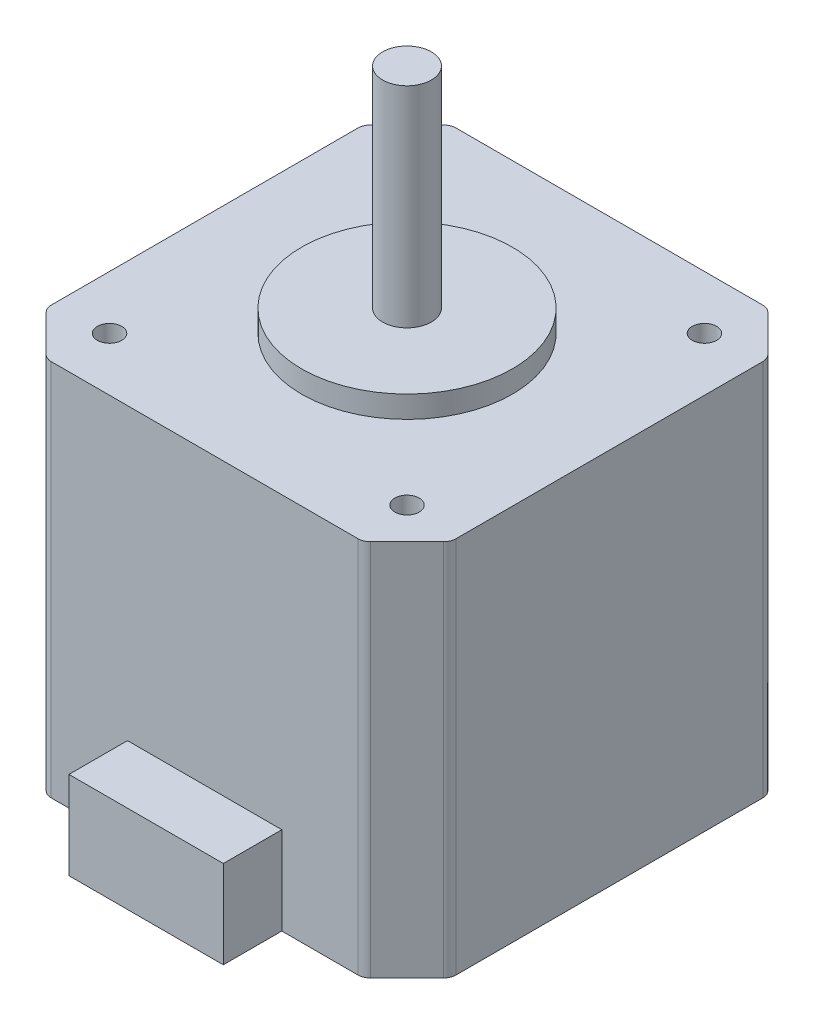
from build123d import *

# Parameters (mm, degrees)
BOSS_EXTRUDE1_DEPTH = 39.37
SKETCH1_3_W         = 16.0782
SKETCH1_3_H         = 6.096
BOSS_EXTRUDE2_DEPTH = 9.144
SKETCH2_R           = 10.9855
BOSS_EXTRUDE3_DEPTH = 2.286
SKETCH3_R           = 2.54
BOSS_EXTRUDE4_DEPTH = 21.844
SKETCH4_R           = 1.27
CUT_EXTRUDE1_DEPTH  = 6.35
CUT_EXTRUDE2_DEPTH  = 53.278975774
FILLET1_R           = 1.27


with BuildPart() as part:
    # Sketch1 → Boss-Extrude1 (new body)
    with BuildSketch(Plane(origin=(0, 0, 0), x_dir=(1, 0, 0), z_dir=(0, 1, 0))):
        Polygon((-21.082, 21.082), (-21.082, -21.082), (-8.0391, -21.082), (8.0391, -21.082), (21.082, -21.082), (21.082, 21.082), align=None)
    extrude(amount=BOSS_EXTRUDE1_DEPTH)

    # Sketch1_3 → Boss-Extrude2 (add)
    with BuildSketch(Plane(origin=(0, 0, 0), x_dir=(1, 0, 0), z_dir=(0, 1, 0))):
        with Locations((0, -24.13)):
            Rectangle(SKETCH1_3_W, SKETCH1_3_H)
    extrude(amount=BOSS_EXTRUDE2_DEPTH)

    # Sketch2 → Boss-Extrude3 (add)
    with BuildSketch(Plane(origin=(0, 39.37, 0), x_dir=(1, 0, 0), z_dir=(0, 1, 0))):
        Circle(SKETCH2_R)
    extrude(amount=BOSS_EXTRUDE3_DEPTH)

    # Sketch3 → Boss-Extrude4 (add)
    with BuildSketch(Plane(origin=(0, 41.656, 0), x_dir=(1, 0, 0), z_dir=(0, 1, 0))):
        Circle(SKETCH3_R)
    extrude(amount=BOSS_EXTRUDE4_DEPTH)

    # Sketch4 → Cut-Extrude1 (cut)
    with BuildSketch(Plane(origin=(0, 39.37, 0), x_dir=(1, 0, 0), z_dir=(0, 1, 0))):
        with Locations((-15.494, 15.494)):
            Circle(SKETCH4_R)
        with Locations((15.494, 15.494)):
            Circle(SKETCH4_R)
        with Locations((15.494, -15.494)):
            Circle(SKETCH4_R)
        with Locations((-15.494, -15.494)):
            Circle(SKETCH4_R)
    extrude(amount=-CUT_EXTRUDE1_DEPTH, mode=Mode.SUBTRACT)

    # Sketch5 → Cut-Extrude2 (cut, through all)
    with BuildSketch(Plane(origin=(0, 39.37, 0), x_dir=(1, 0, 0), z_dir=(0, 1, 0))):
        Polygon((-21.082, 16.51), (-16.51, 21.082), (-21.082, 21.082), align=None)
        Polygon((16.51, 21.082), (21.082, 16.51), (21.082, 21.082), align=None)
        Polygon((21.082, -16.51), (16.51, -21.082), (21.082, -21.082), align=None)
        Polygon((-16.51, -21.082), (-21.082, -16.51), (-21.082, -21.082), align=None)
    extrude(amount=-CUT_EXTRUDE2_DEPTH, mode=Mode.SUBTRACT)

    # Fillet1
    fillet1_edges = [part.edges().sort_by_distance(p)[0] for p in [
        (-21.082, 19.685, -16.51),
        (-16.51, 19.685, -21.082),
        (16.51, 19.685, -21.082),
        (21.082, 19.685, -16.51),
        (21.082, 19.685, 16.51),
        (16.51, 19.685, 21.082),
        (-21.082, 19.685, 16.51),
        (-16.51, 19.685, 21.082),
    ]]
    fillet(fillet1_edges, radius=FILLET1_R)


solid = part.part
